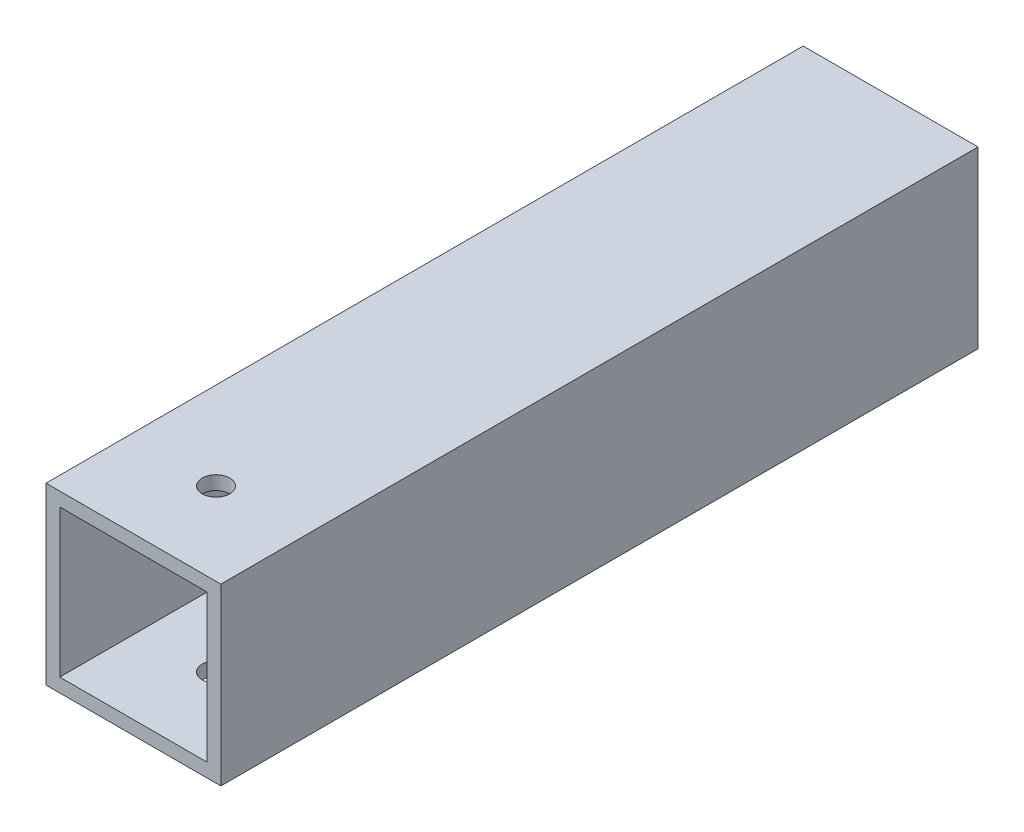
from build123d import *

# Parameters (mm, degrees)
SKETCH1_W           = 25.4
SKETCH1_H           = 25.4
SKETCH1_W_2         = 21.4
SKETCH1_H_2         = 21.4
BOSS_EXTRUDE1_DEPTH = 110
SKETCH2_R           = 2
CUT_EXTRUDE1_DEPTH  = 26.4


with BuildPart() as part:
    # Sketch1 → Boss-Extrude1 (new body)
    with BuildSketch(Plane.XY):
        with Locations((12.7, 12.7)):
            Rectangle(SKETCH1_W, SKETCH1_H)
        with Locations((12.7, 12.7)):
            Rectangle(SKETCH1_W_2, SKETCH1_H_2, mode=Mode.SUBTRACT)
    extrude(amount=BOSS_EXTRUDE1_DEPTH)

    # Sketch2 → Cut-Extrude1 (cut, through all)
    with BuildSketch(Plane.XZ):
        with Locations((12.7, 98)):
            Circle(SKETCH2_R)
    extrude(amount=-CUT_EXTRUDE1_DEPTH, mode=Mode.SUBTRACT)


solid = part.part
